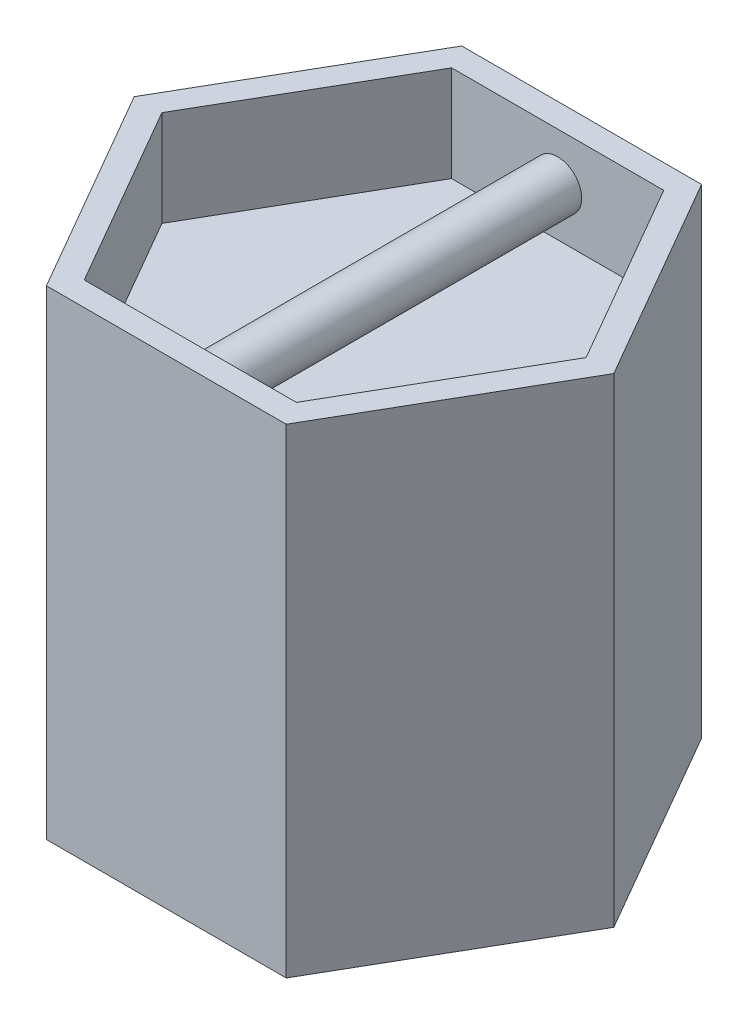
from build123d import *

# Parameters (mm, degrees)
BOSS_EXTRUDE1_DEPTH             = 20
CUT_EXTRUDE1_DEPTH              = 4
BOSS_EXTRUDE2_REACH             = 10.66
SKETCH4_R                       = 1
BOSS_EXTRUDE2_DIRECTION_2_REACH = 10.66


with BuildPart() as part:
    # Sketch1 → Boss-Extrude1 (new body)
    with BuildSketch(Plane(origin=(0, 0, 0), x_dir=(1, 0, 0), z_dir=(0, 1, 0))):
        Polygon((10, 0), (5, 8.660254038), (-5, 8.660254038), (-10, 0), (-5, -8.660254038), (5, -8.660254038), align=None)
    extrude(amount=BOSS_EXTRUDE1_DEPTH)

    # Sketch3 → Cut-Extrude1 (cut)
    with BuildSketch(Plane(origin=(0, 20, 0), x_dir=(1, 0, 0), z_dir=(0, 1, 0))):
        Polygon((4.422649731, -7.660254038), (8.845299462, 0), (4.422649731, 7.660254038), (-4.422649731, 7.660254038), (-8.845299462, 0), (-4.422649731, -7.660254038), align=None)
    extrude(amount=-CUT_EXTRUDE1_DEPTH, mode=Mode.SUBTRACT)

    # Sketch4 → Boss-Extrude2 (add, up to next)
    with BuildSketch(Plane.XY, mode=Mode.PRIVATE) as boss_extrude2_sk1:
        with Locations((0, 18)):
            Circle(SKETCH4_R)
    boss_extrude2_tool1 = extrude(boss_extrude2_sk1.sketch, amount=BOSS_EXTRUDE2_REACH, mode=Mode.PRIVATE) - part.part
    add(boss_extrude2_tool1.solids().sort_by_distance((0, 18, 0))[0])

    # Sketch4 → Boss-Extrude2 direction 2 (add, up to next)
    with BuildSketch(Plane.XY, mode=Mode.PRIVATE) as boss_extrude2_direction_2_sk1:
        with Locations((0, 18)):
            Circle(SKETCH4_R)
    boss_extrude2_direction_2_tool1 = extrude(boss_extrude2_direction_2_sk1.sketch, amount=-BOSS_EXTRUDE2_DIRECTION_2_REACH, mode=Mode.PRIVATE) - part.part
    add(boss_extrude2_direction_2_tool1.solids().sort_by_distance((0, 18, 0))[0])


solid = part.part
